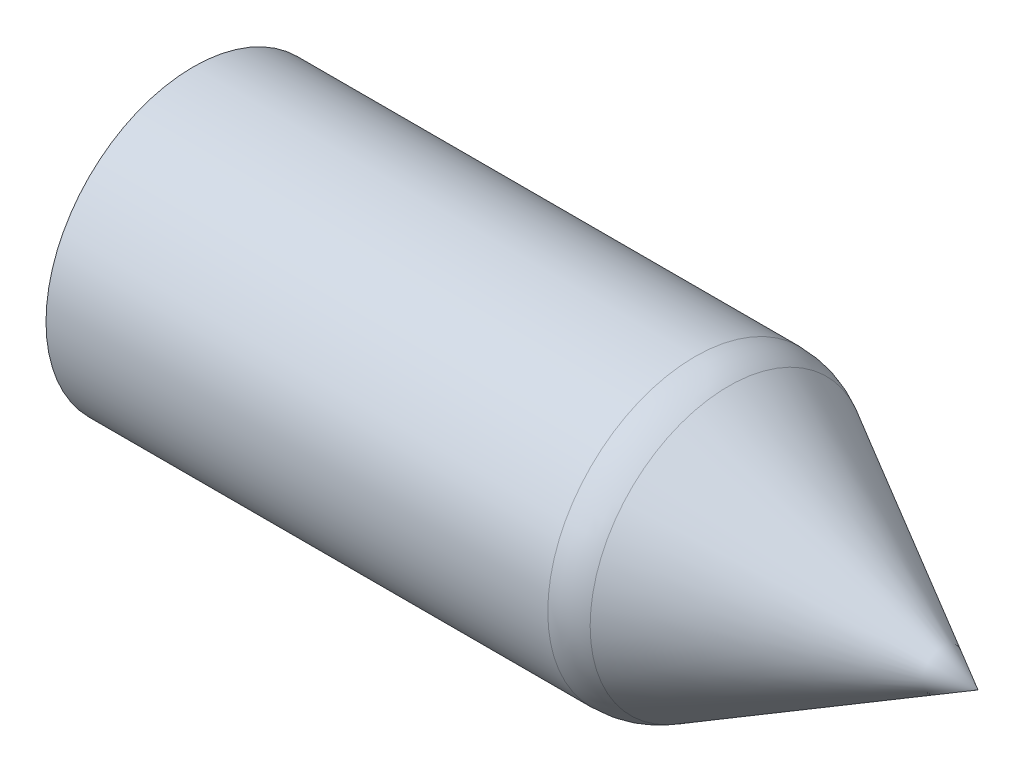
from build123d import *

# Parameters (mm, degrees)
VERRUNDUNG1_R = 2


with BuildPart() as part:
    # Skizze1 → Rotation1 (revolve)
    with BuildSketch(Plane(origin=(0, 0, 0), x_dir=(1, 0, 0), z_dir=(0, 1, 0)), mode=Mode.PRIVATE) as rotation1_sk:
        Polygon((0, 0), (-7.64852927, 4.25), (-22.64852927, 4.25), (-22.64852927, 0), align=None)
    revolve(rotation1_sk.sketch.rotate(Axis((0, 0, 0), (-1, 0, 0)), 180), axis=Axis((0, 0, 0), (-1, 0, 0)))  # turned: the seam where the file's is

    # Verrundung1
    verrundung1_edges = [part.edges().sort_by_distance(p)[0] for p in [
        (-7.64852927, 0, -4.25),
    ]]
    fillet(verrundung1_edges, radius=VERRUNDUNG1_R)


solid = part.part
